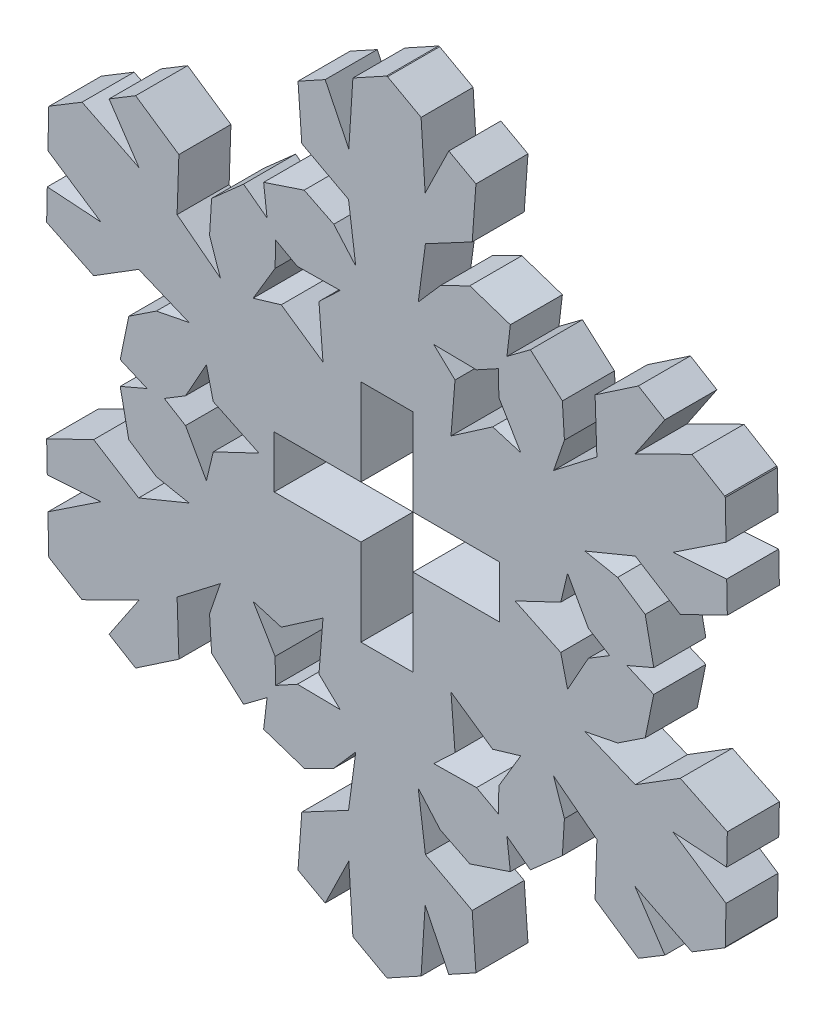
from build123d import *

# Parameters (mm, degrees)
EXTRUDE_1_DEPTH = 3


with BuildPart() as part:
    # Model → Бобышка-Вытянуть1 (new body)
    with BuildSketch(Plane.XY):
        Polygon((0, 45), (1.932, 43.9368), (2.1657, 40.274), (3.5293, 43.0577), (5.095, 42.1961), (4.8781, 39.1897), (2.1828, 37.7532), (1.768, 34.6339), (3.0349, 36.0833), (4.741, 36.9329), (7.0776, 36.1545), (6.8807, 34.477), (8.2351, 35.4863), (10.0775, 33.8519), (10.1947, 31.9495), (9.573, 30.1277), (12.067, 32.0465), (11.9634, 35.099), (14.4585, 36.79), (15.9876, 35.8649), (14.2586, 33.2921), (17.5475, 34.9212), (19.4343, 33.7796), (19.4685, 33.7204), (19.5137, 31.5156), (16.4584, 29.4818), (19.5511, 29.6928), (19.5877, 27.906), (16.8757, 26.5907), (14.284, 28.2067), (11.3752, 27.0062), (13.2638, 26.6337), (14.8527, 25.5811), (15.3469, 23.1682), (13.7956, 22.5), (15.3469, 21.8318), (14.8527, 19.4189), (13.2637, 18.3662), (11.3752, 17.9938), (14.284, 16.7933), (16.8757, 18.4093), (19.5877, 17.094), (19.5511, 15.3072), (16.4584, 15.5182), (19.5137, 13.4844), (19.4685, 11.2796), (19.4343, 11.2204), (17.5475, 10.0788), (14.2586, 11.7079), (15.9876, 9.1351), (14.4585, 8.21), (11.9634, 9.901), (12.067, 12.9534), (9.5729, 14.8723), (10.1947, 13.0505), (10.0775, 11.1481), (8.2351, 9.5137), (6.8807, 10.523), (7.0776, 8.8455), (4.741, 8.0671), (3.0348, 8.9168), (1.768, 10.3661), (2.1828, 7.2468), (4.8781, 5.8103), (5.095, 2.8039), (3.5293, 1.9422), (2.1657, 4.726), (1.932, 1.0632), (0, 0), (-0.0684, 0), (-2.0003, 1.0632), (-2.2341, 4.726), (-3.5977, 1.9423), (-5.1634, 2.8039), (-4.9465, 5.8103), (-2.2512, 7.2468), (-1.8364, 10.3661), (-3.1033, 8.9167), (-4.8093, 8.0671), (-7.146, 8.8455), (-6.9491, 10.523), (-8.3034, 9.5137), (-10.1459, 11.1481), (-10.2631, 13.0505), (-9.6414, 14.8723), (-12.1354, 12.9534), (-12.0318, 9.901), (-14.5269, 8.21), (-16.056, 9.1351), (-14.327, 11.7079), (-17.6159, 10.0788), (-19.5027, 11.2204), (-19.5369, 11.2796), (-19.5821, 13.4844), (-16.5268, 15.5182), (-19.6194, 15.3072), (-19.6561, 17.094), (-16.944, 18.4093), (-14.3524, 16.7933), (-11.4436, 17.9938), (-13.3322, 18.3663), (-14.9211, 19.4189), (-15.4153, 21.8318), (-13.864, 22.5), (-15.4153, 23.1682), (-14.9211, 25.5811), (-13.3321, 26.6338), (-11.4436, 27.0062), (-14.3524, 28.2067), (-16.944, 26.5907), (-19.6561, 27.906), (-19.6195, 29.6928), (-16.5268, 29.4818), (-19.5821, 31.5156), (-19.5369, 33.7204), (-19.5027, 33.7796), (-17.6159, 34.9212), (-14.327, 33.2921), (-16.0559, 35.8649), (-14.5269, 36.79), (-12.0318, 35.099), (-12.1354, 32.0465), (-9.6413, 30.1277), (-10.2631, 31.9495), (-10.1459, 33.8519), (-8.3034, 35.4863), (-6.9491, 34.477), (-7.146, 36.1545), (-4.8093, 36.9329), (-3.1032, 36.0832), (-1.8364, 34.6339), (-2.2512, 37.7532), (-4.9465, 39.1897), (-5.1634, 42.1961), (-3.5977, 43.0577), (-2.2341, 40.274), (-2.0003, 43.9368), (-0.0684, 45), align=None)
        Polygon((6.385, 33.6184), (5.1294, 32.9309), (2.6621, 32.9644), (3.8879, 31.8023), (3.6555, 28.8908), (6.0609, 30.5478), (7.6801, 30.0673), (6.4174, 32.1872), align=None, mode=Mode.SUBTRACT)
        Polygon((1.4658, 16), (1.4658, 21), (6.4658, 21), (6.4658, 24), (1.4658, 24), (1.4658, 29), (-1.5342, 29), (-1.5342, 24), (-6.5342, 24), (-6.5342, 21), (-1.5342, 21), (-1.5342, 16), align=None, mode=Mode.SUBTRACT)
        Polygon((-12.8726, 22.5), (-11.6494, 21.7564), (-10.4448, 19.6029), (-10.0513, 21.2454), (-7.4136, 22.5), (-10.0513, 23.7546), (-10.4448, 25.3971), (-11.6494, 23.2436), align=None, mode=Mode.SUBTRACT)
        Polygon((-3.7239, 28.8908), (-3.9562, 31.8024), (-2.7305, 32.9644), (-5.1978, 32.9309), (-6.4534, 33.6184), (-6.4858, 32.1872), (-7.7485, 30.0673), (-6.1292, 30.5478), align=None, mode=Mode.SUBTRACT)
        Polygon((12.8042, 22.5), (11.581, 23.2436), (10.3764, 25.3971), (9.9829, 23.7546), (7.3452, 22.5), (9.9829, 21.2454), (10.3764, 19.6029), (11.581, 21.7564), align=None, mode=Mode.SUBTRACT)
        Polygon((6.385, 11.3816), (6.4174, 12.8128), (7.6801, 14.9327), (6.0608, 14.4522), (3.6555, 16.1092), (3.8878, 13.1976), (2.6621, 12.0356), (5.1294, 12.0691), align=None, mode=Mode.SUBTRACT)
        Polygon((-6.4534, 11.3816), (-5.1978, 12.0691), (-2.7305, 12.0356), (-3.9563, 13.1977), (-3.7239, 16.1092), (-6.1292, 14.4522), (-7.7485, 14.9327), (-6.4858, 12.8128), align=None, mode=Mode.SUBTRACT)
    extrude(amount=EXTRUDE_1_DEPTH)


solid = part.part
